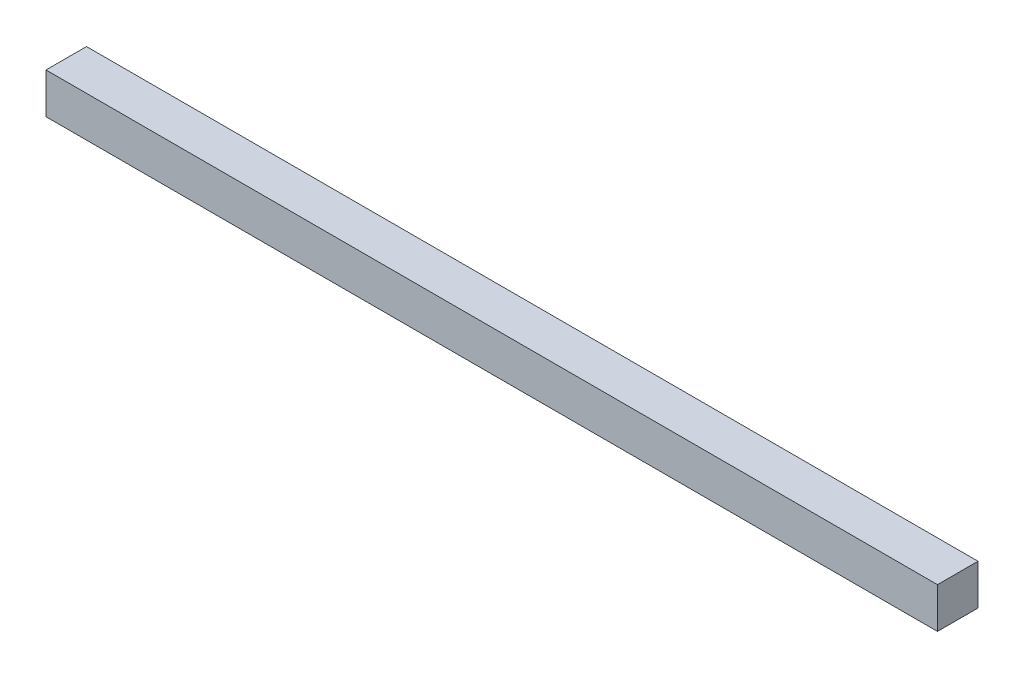
from build123d import *

# Parameters (mm, degrees)
ESQUISSE1_W        = 11000
ESQUISSE1_H        = 500
BOSS_EXTRU_1_DEPTH = 500


with BuildPart() as part:
    # Esquisse1 → Boss.-Extru.1 (new body)
    with BuildSketch(Plane.XY):
        Rectangle(ESQUISSE1_W, ESQUISSE1_H)
    extrude(amount=BOSS_EXTRU_1_DEPTH)


solid = part.part
